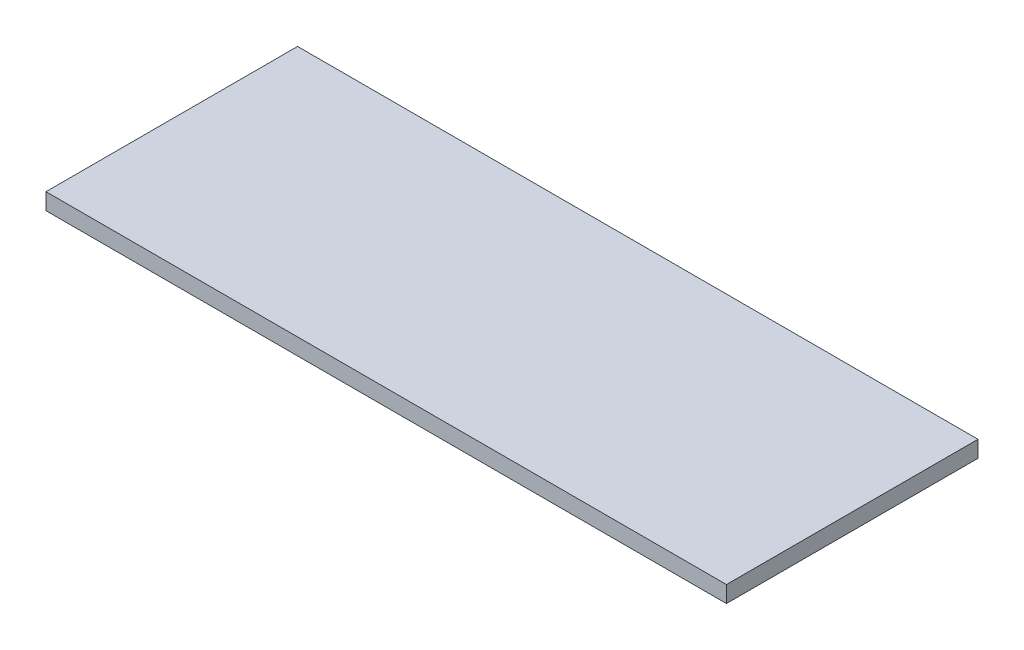
from build123d import *

# Parameters (mm, degrees)
SKETCH1_W           = 165
SKETCH1_H           = 61
BOSS_EXTRUDE1_DEPTH = 4


with BuildPart() as part:
    # Sketch1 → Boss-Extrude1 (new body)
    with BuildSketch(Plane(origin=(0, 0, 0), x_dir=(1, 0, 0), z_dir=(0, 1, 0))):
        Rectangle(SKETCH1_W, SKETCH1_H)
    extrude(amount=BOSS_EXTRUDE1_DEPTH)


solid = part.part
